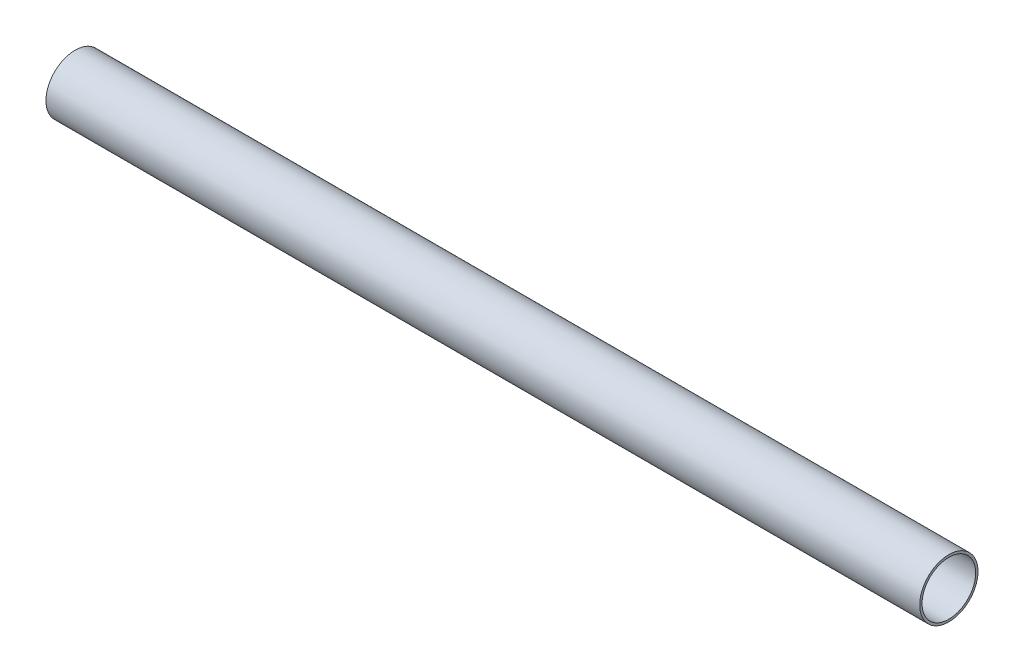
from build123d import *

# Parameters (mm, degrees)
SKETCH1_R           = 25
SKETCH1_R_2         = 23
BOSS_EXTRUDE1_DEPTH = 749.3


with BuildPart() as part:
    # Sketch1 → Boss-Extrude1 (new body)
    with BuildSketch(Plane(origin=(0, 0, 0), x_dir=(0, 0, -1), z_dir=(1, 0, 0))):
        Circle(SKETCH1_R)
        Circle(SKETCH1_R_2, mode=Mode.SUBTRACT)
    extrude(amount=BOSS_EXTRUDE1_DEPTH)


solid = part.part
